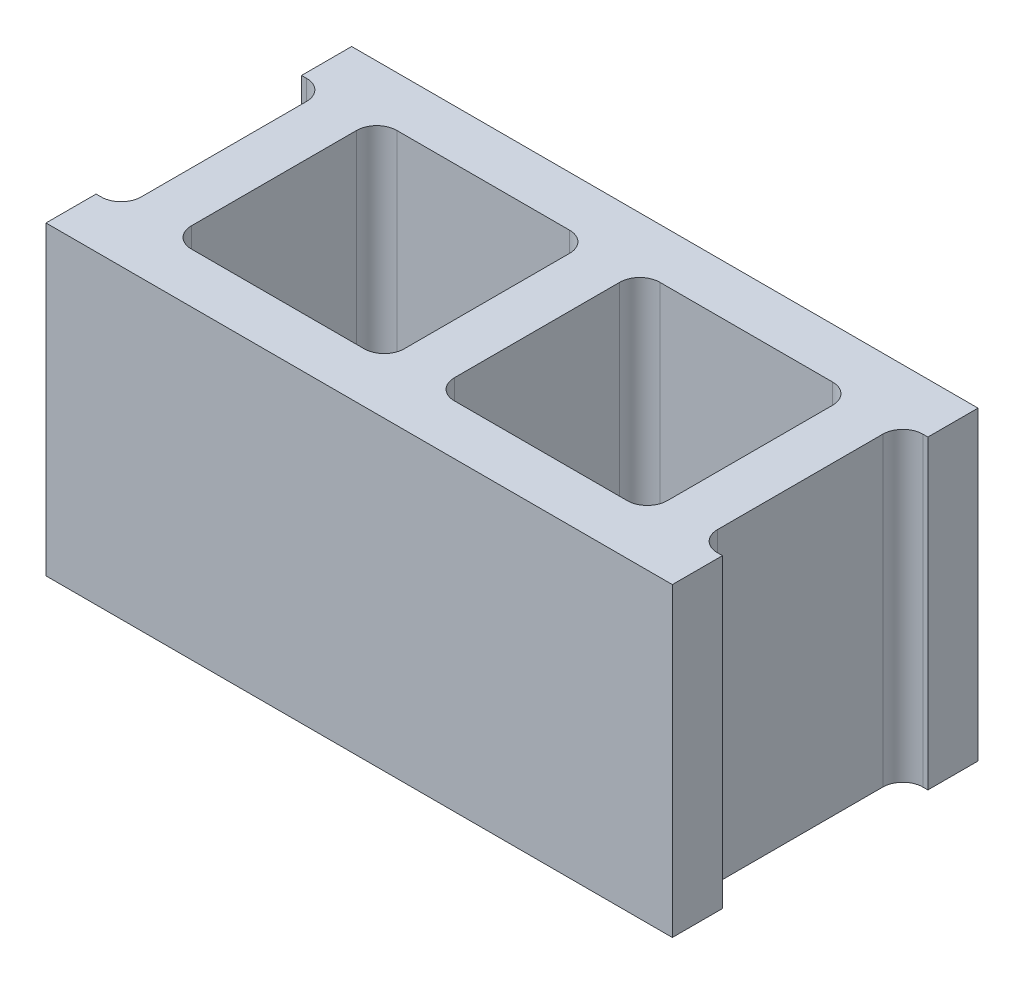
from build123d import *

# Parameters (mm, degrees)
EXTRUDE1_DEPTH = 193.675


with BuildPart() as part:
    # Sketch1 → Extrude1 (new body)
    with BuildSketch(Plane(origin=(0, 0, 0), x_dir=(1, 0, 0), z_dir=(0, 1, 0))):
        with BuildLine():
            Line((-198.4375, 65.0875), (-195.2625, 65.0875))
            ThreePointArc((-195.2625, 65.0875), (-186.282243879, 61.367756121), (-182.5625, 52.3875))
            Line((-182.5625, 52.3875), (-182.5625, -52.3875))
            ThreePointArc((-182.5625, -52.3875), (-186.282243879, -61.367756121), (-195.2625, -65.0875))
            Line((-195.2625, -65.0875), (-198.4375, -65.0875))
            Line((-198.4375, -65.0875), (-198.4375, -96.8375))
            Line((-198.4375, -96.8375), (198.4375, -96.8375))
            Line((198.4375, -96.8375), (198.4375, -65.0875))
            Line((198.4375, -65.0875), (195.2625, -65.0875))
            ThreePointArc((195.2625, -65.0875), (186.282243879, -61.367756121), (182.5625, -52.3875))
            Line((182.5625, -52.3875), (182.5625, 52.3875))
            ThreePointArc((182.5625, 52.3875), (186.282243879, 61.367756121), (195.2625, 65.0875))
            Line((195.2625, 65.0875), (198.4375, 65.0875))
            Line((198.4375, 65.0875), (198.4375, 96.8375))
            Line((198.4375, 96.8375), (-198.4375, 96.8375))
            Line((-198.4375, 96.8375), (-198.4375, 65.0875))
        make_face()
        with BuildLine():
            Line((-28.575, -65.0875), (-138.1125, -65.0875))
            ThreePointArc((-138.1125, -65.0875), (-147.092756121, -61.367756121), (-150.8125, -52.3875))
            Line((-150.8125, -52.3875), (-150.8125, 52.3875))
            ThreePointArc((-150.8125, 52.3875), (-147.092756121, 61.367756121), (-138.1125, 65.0875))
            Line((-138.1125, 65.0875), (-28.575, 65.0875))
            ThreePointArc((-28.575, 65.0875), (-19.594743879, 61.367756121), (-15.875, 52.3875))
            Line((-15.875, 52.3875), (-15.875, -52.3875))
            ThreePointArc((-15.875, -52.3875), (-19.594743879, -61.367756121), (-28.575, -65.0875))
        make_face(mode=Mode.SUBTRACT)
        with BuildLine():
            Line((138.1125, -65.0875), (28.575, -65.0875))
            ThreePointArc((28.575, -65.0875), (19.594743879, -61.367756121), (15.875, -52.3875))
            Line((15.875, -52.3875), (15.875, 52.3875))
            ThreePointArc((15.875, 52.3875), (19.594743879, 61.367756121), (28.575, 65.0875))
            Line((28.575, 65.0875), (138.1125, 65.0875))
            ThreePointArc((138.1125, 65.0875), (147.092756121, 61.367756121), (150.8125, 52.3875))
            Line((150.8125, 52.3875), (150.8125, -52.3875))
            ThreePointArc((150.8125, -52.3875), (147.092756121, -61.367756121), (138.1125, -65.0875))
        make_face(mode=Mode.SUBTRACT)
    extrude(amount=EXTRUDE1_DEPTH)


solid = part.part
